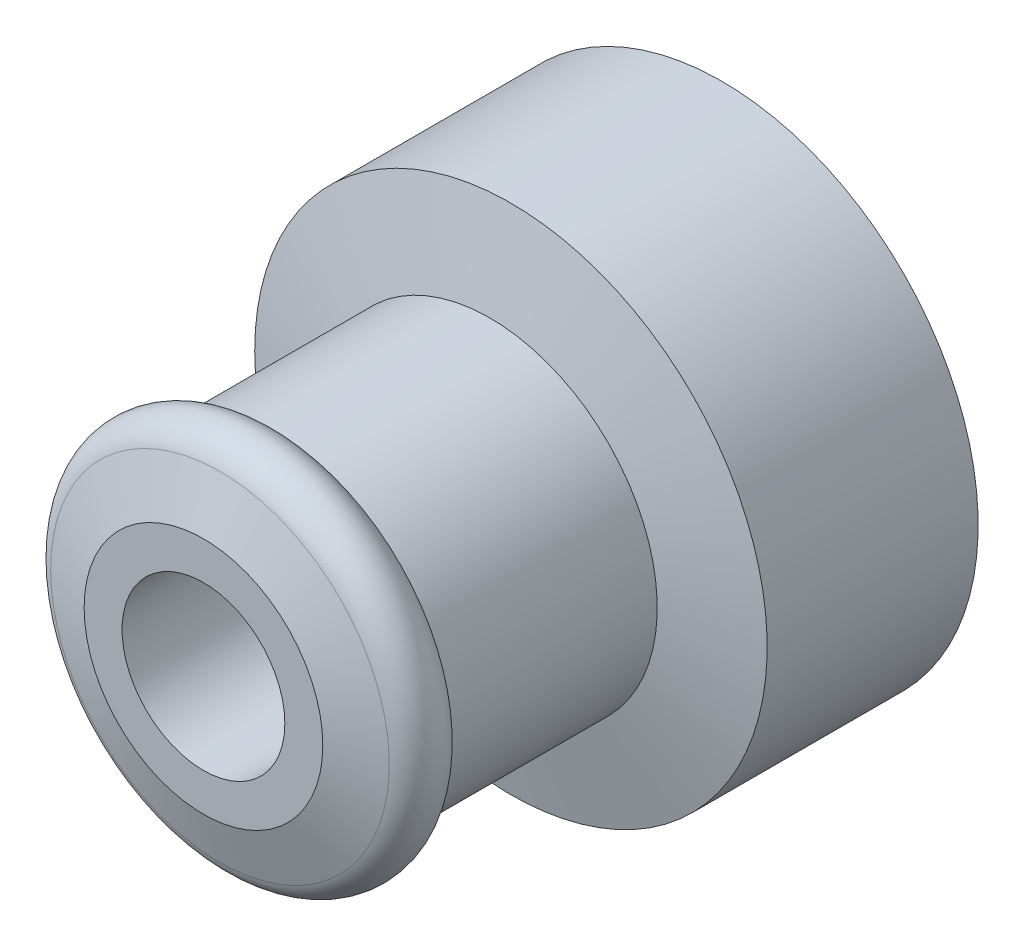
from build123d import *

# Parameters (mm, degrees)
BORE_START          = 1
SKETCH_2_R          = 2.7
BORE_DEPTH          = 22.98427983
FIX_START           = 3.2
SKETCH_4_R          = 1.7
FIX_2_DEPTH         = 18.78427983
CUT_EXTRUDE_START   = 2.5
CUT_EXTRUDE_1_DEPTH = 2.8
MOVE_BODY_1_ANGLE   = 90
FILLET_1_R          = 0.15


with BuildPart() as part:
    # Эскиз1 → Body (revolve)
    with BuildSketch(Plane.XY):
        with BuildLine():
            Line((0, 8.5), (0, 0))
            Line((0, 0), (17.2, 0))
            Line((17.2, 0), (17.2, 3.958583851))
            Line((17.2, 3.958583851), (16.652924896, 5.61704678))
            ThreePointArc((16.652924896, 5.61704678), (15.650028154, 6.31642018), (14.697387016, 5.55))
            Line((14.697387016, 5.55), (7.697387016, 5.55))
            Line((7.697387016, 5.55), (7, 8.5))
            Line((7, 8.5), (0, 8.5))
        make_face()
    revolve(axis=Axis((0, 0, 0), (1, 0, 0)))

    # Эскиз2 → Bore (cut, through all)
    with BuildSketch(Plane(origin=(17.2, 0, 0), x_dir=(0, 0, -1), z_dir=(1, 0, 0)).offset(BORE_START)):
        Circle(SKETCH_2_R)
    extrude(amount=-BORE_DEPTH, mode=Mode.SUBTRACT)

    # Эскиз4 → Fix 2 (cut, through all)
    with BuildSketch(Plane.XY.offset(FIX_START)):
        with Locations((3.5, 0)):
            Circle(SKETCH_4_R)
    extrude(amount=FIX_2_DEPTH, mode=Mode.SUBTRACT)

    # Эскиз4<3> → Вырез-Вытянуть1 (cut)
    with BuildSketch(Plane.XY.offset(CUT_EXTRUDE_START)):
        Polygon((5.120135639, 2.806157241), (-1.112463997, 2.806157241), (-1.112463997, -2.806157241), (5.120135639, -2.806157241), (6.740271277, 0), align=None)
    extrude(amount=CUT_EXTRUDE_1_DEPTH, mode=Mode.SUBTRACT)


with BuildPart() as part_1:
    # Move Body 1: moved
    add(part.part.rotate(Axis((8, 0, 0), (0, -1, 0)), MOVE_BODY_1_ANGLE))

    # Скругление1
    fillet_1_edges = [part_1.edges().sort_by_distance(p)[0] for p in [
        (5.5, -1.019803903, -4.92425639),
        (5.5, 1.019803903, -4.92425639),
    ]]
    fillet(fillet_1_edges, radius=FILLET_1_R)


solid = part_1.part
